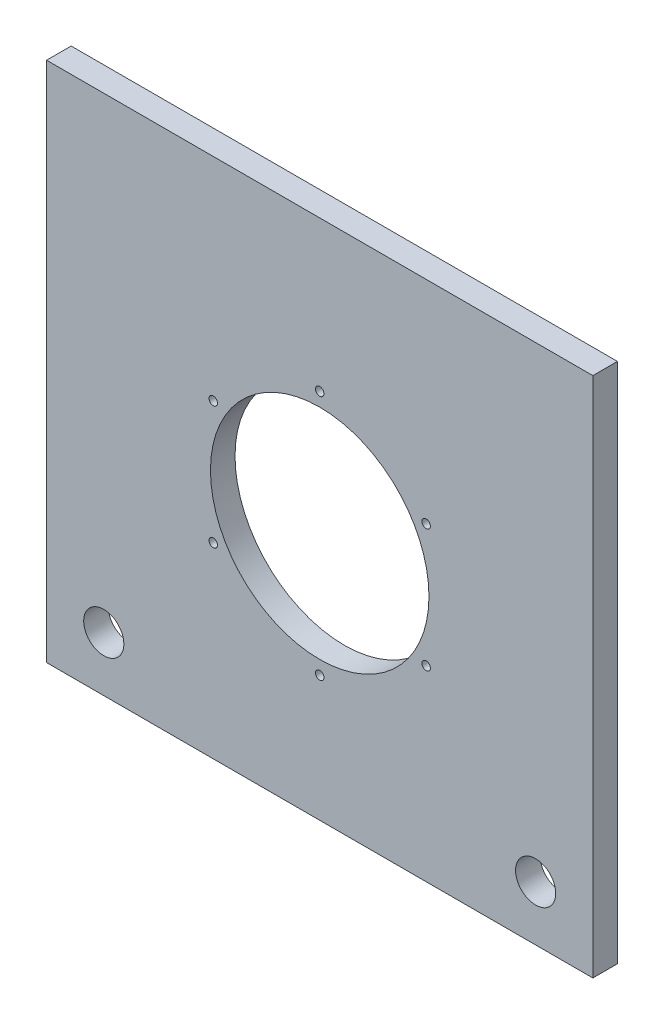
from build123d import *

# Parameters (mm, degrees)
SKETCH_1_W      = 200
SKETCH_1_H      = 191
SKETCH_1_R      = 40
SKETCH_1_R_2    = 7.35
SKETCH_1_R_3    = 1.55
EXTRUDE_1_DEPTH = 9


with BuildPart() as part:
    # 草图1 → 凸台-拉伸1 (new body)
    with BuildSketch(Plane.XY):
        Rectangle(SKETCH_1_W, SKETCH_1_H)
        with Locations((0, -4.5)):
            Circle(SKETCH_1_R, mode=Mode.SUBTRACT)
        with Locations((-79.057591623, -75.5)):
            Circle(SKETCH_1_R_2, mode=Mode.SUBTRACT)
        with Locations((79.057591623, -75.5)):
            Circle(SKETCH_1_R_2, mode=Mode.SUBTRACT)
        with Locations((0, 40.5)):
            Circle(SKETCH_1_R_3, mode=Mode.SUBTRACT)
        with Locations((38.97114317, 18)):
            Circle(SKETCH_1_R_3, mode=Mode.SUBTRACT)
        with Locations((38.97114317, -27)):
            Circle(SKETCH_1_R_3, mode=Mode.SUBTRACT)
        with Locations((0, -49.5)):
            Circle(SKETCH_1_R_3, mode=Mode.SUBTRACT)
        with Locations((-38.97114317, -27)):
            Circle(SKETCH_1_R_3, mode=Mode.SUBTRACT)
        with Locations((-38.97114317, 18)):
            Circle(SKETCH_1_R_3, mode=Mode.SUBTRACT)
    extrude(amount=EXTRUDE_1_DEPTH)


solid = part.part
